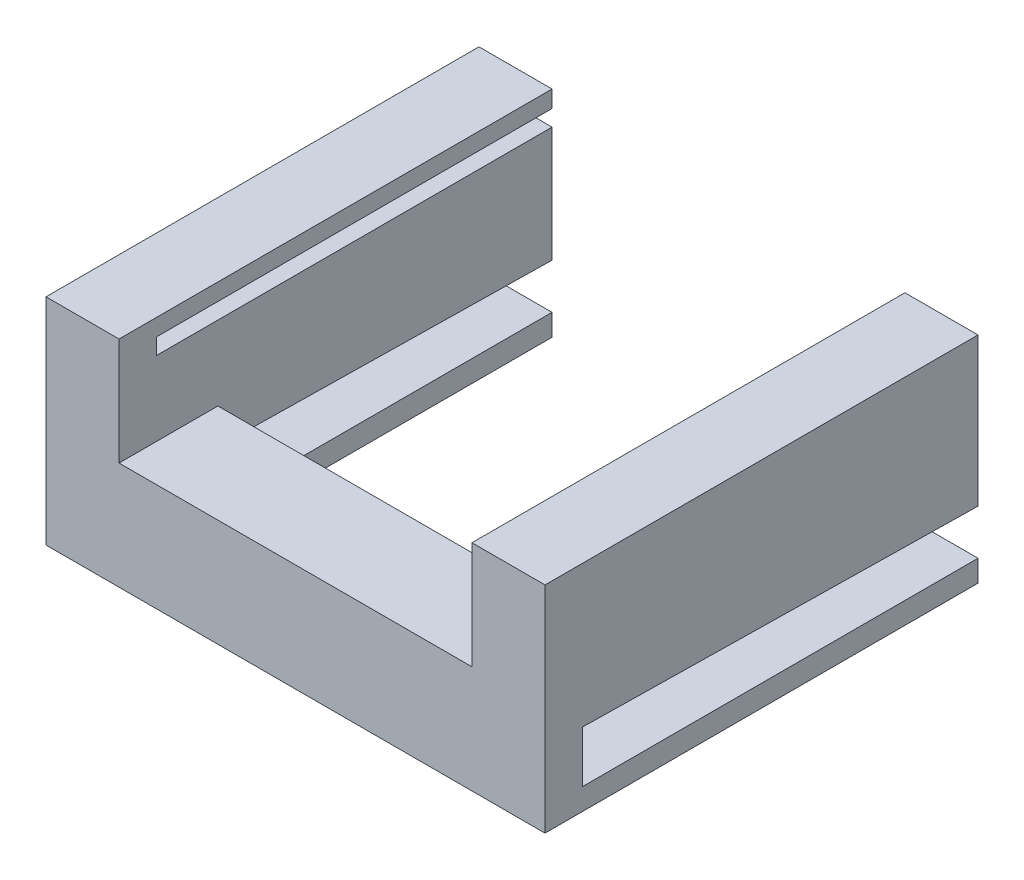
from build123d import *

# Parameters (mm, degrees)
BOSS_EXTRUDE1_DEPTH = 22.86
SKETCH3_R           = 27.372592865
CUT_EXTRUDE1_DEPTH  = 69.240761179
SKETCH4_R           = 26.837944266
CUT_EXTRUDE2_DEPTH  = 64.339651167
BOSS_EXTRUDE2_START = 22.86
SKETCH2_3_W         = 2.286
SKETCH2_3_H         = 2.286
SKETCH2_3_R         = 1.05
SKETCH2_3_H_2       = 9.395
BOSS_EXTRUDE2_DEPTH = 12.7
SKETCH5_W           = 49.53
SKETCH5_H           = 1.9
CUT_EXTRUDE4_DEPTH  = 46.736
SKETCH6_W           = 51.181
SKETCH6_H           = 10.146462019
CUT_EXTRUDE5_DEPTH  = 74.476087969


with BuildPart() as part:
    # Sketch2 → Boss-Extrude1 (new body)
    with BuildSketch(Plane(origin=(0, 0, 0), x_dir=(1, 0, 0), z_dir=(0, 1, 0))):
        Polygon((29.493, -25.5905), (29.493, 25.5905), (20.857, 25.5905), (20.857, -13.9095), (-20.857, -13.9095), (-20.857, 25.5905), (-29.493, 25.5905), (-29.493, -25.5905), align=None)
    extrude(amount=BOSS_EXTRUDE1_DEPTH)

    # Sketch3 → Cut-Extrude1 (cut, through all)
    with BuildSketch(Plane(origin=(29.493, 0, 0), x_dir=(0, 0, -1), z_dir=(1, 0, 0))):
        with Locations((2.032, -17.226130846)):
            Circle(SKETCH3_R)
        Polygon((25.5905, 12.7), (-21.1455, 12.7), (-21.1455, 18.796), (25.5905, 18.034), align=None)
    extrude(amount=-CUT_EXTRUDE1_DEPTH, mode=Mode.SUBTRACT)

    # Sketch4 → Cut-Extrude2 (cut, through all)
    with BuildSketch(Plane(origin=(0, 0, -25.5905), x_dir=(-1, 0, 0), z_dir=(0, 0, -1))):
        with Locations((0, -16.88966558)):
            Circle(SKETCH4_R)
    extrude(amount=-CUT_EXTRUDE2_DEPTH, mode=Mode.SUBTRACT)

    # Sketch2_3 → Boss-Extrude2 (add)
    with BuildSketch(Plane(origin=(0, 0, 0), x_dir=(1, 0, 0), z_dir=(0, 1, 0)).offset(BOSS_EXTRUDE2_START)):
        with Locations((22, 24.4475)):
            Rectangle(SKETCH2_3_W, SKETCH2_3_H)
        with Locations((22, 24.4475)):
            Circle(SKETCH2_3_R, mode=Mode.SUBTRACT)
        with Locations((22, -15.0525)):
            Rectangle(SKETCH2_3_W, SKETCH2_3_H)
        with Locations((22, -15.0525)):
            Circle(SKETCH2_3_R, mode=Mode.SUBTRACT)
        with Locations((-22, -15.0525)):
            Rectangle(SKETCH2_3_W, SKETCH2_3_H)
        with Locations((-22, -15.0525)):
            Circle(SKETCH2_3_R, mode=Mode.SUBTRACT)
        with Locations((-22, 24.4475)):
            Rectangle(SKETCH2_3_W, SKETCH2_3_H)
        with Locations((-22, 24.4475)):
            Circle(SKETCH2_3_R, mode=Mode.SUBTRACT)
        Polygon((29.493, 25.5905), (23.143, 25.5905), (23.143, 23.3045), (23.143, -13.9095), (23.143, -16.1955), (23.143, -25.5905), (29.493, -25.5905), align=None)
        with Locations((22, -20.893)):
            Rectangle(SKETCH2_3_W, SKETCH2_3_H_2)
        with Locations((-22, -20.893)):
            Rectangle(SKETCH2_3_W, SKETCH2_3_H_2)
        Polygon((-23.143, 23.3045), (-23.143, 25.5905), (-29.493, 25.5905), (-29.493, -25.5905), (-23.143, -25.5905), (-23.143, -16.1955), (-23.143, -13.9095), align=None)
        with Locations((22, -15.0525)):
            Circle(SKETCH2_3_R)
        with Locations((22, 24.4475)):
            Circle(SKETCH2_3_R)
        Polygon((23.143, -13.9095), (23.143, 23.3045), (20.857, 23.3045), (20.857, 4.6975), (20.857, -13.9095), align=None)
        Polygon((-20.857, 4.6975), (-20.857, 23.3045), (-23.143, 23.3045), (-23.143, -13.9095), (-20.857, -13.9095), align=None)
        with Locations((-22, 24.4475)):
            Circle(SKETCH2_3_R)
        with Locations((-22, -15.0525)):
            Circle(SKETCH2_3_R)
    extrude(amount=BOSS_EXTRUDE2_DEPTH)

    # Sketch5 → Cut-Extrude4 (cut)
    with BuildSketch(Plane(origin=(0, 0, -25.5905), x_dir=(-1, 0, 0), z_dir=(0, 0, -1))):
        with Locations((0, 32.61)):
            Rectangle(SKETCH5_W, SKETCH5_H)
    extrude(amount=-CUT_EXTRUDE4_DEPTH, mode=Mode.SUBTRACT)

    # Sketch6 → Cut-Extrude5 (cut, through all)
    with BuildSketch(Plane(origin=(29.493, 0, 0), x_dir=(0, 0, -1), z_dir=(1, 0, 0))):
        with Locations((0, 5.07323101)):
            Rectangle(SKETCH6_W, SKETCH6_H)
    extrude(amount=-CUT_EXTRUDE5_DEPTH, mode=Mode.SUBTRACT)


solid = part.part
